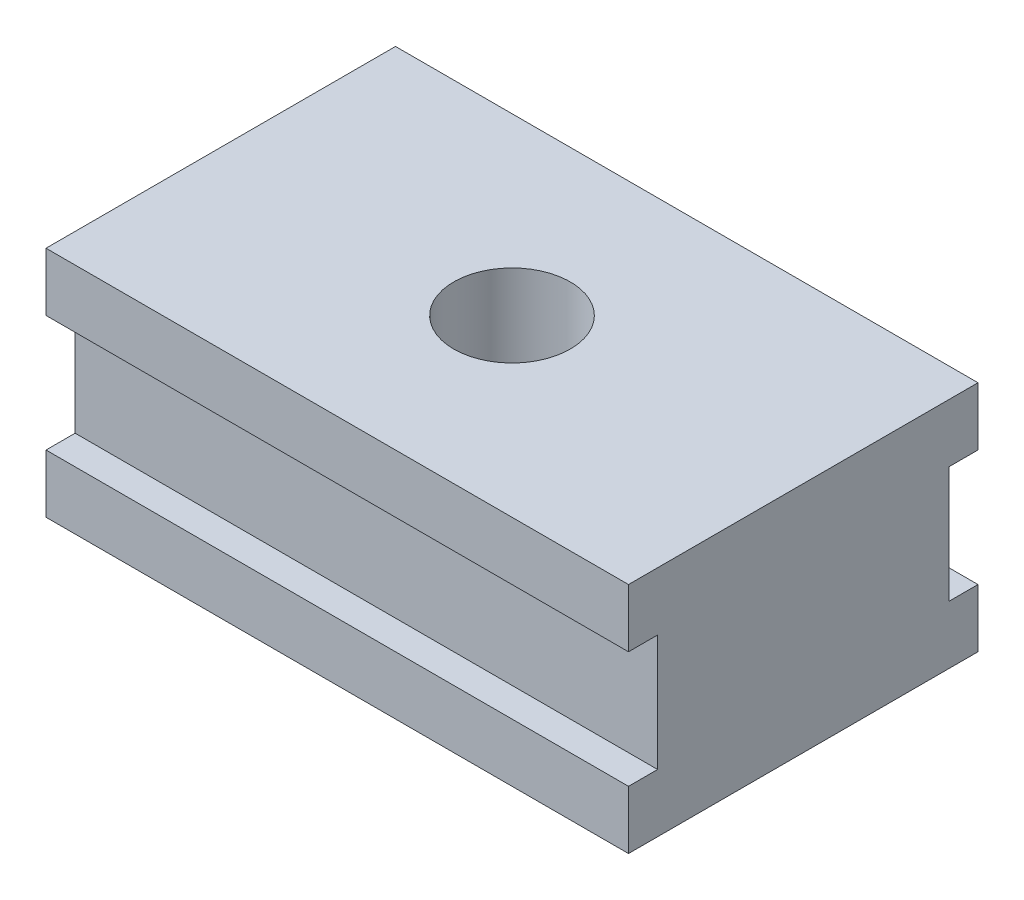
from build123d import *

# Parameters (mm, degrees)
SKETCH_1_W          = 20
SKETCH_1_H          = 8
EXTRUDE_1_DEPTH     = 12
SKETCH_2_W          = 1
SKETCH_2_H          = 4
CUT_EXTRUDE_3_DEPTH = 21
CUT_EXTRUDE_4_DEPTH = 9


with BuildPart() as part:
    # 草图1 → 凸台-拉伸1 (new body)
    with BuildSketch(Plane.XY):
        Rectangle(SKETCH_1_W, SKETCH_1_H)
    extrude(amount=EXTRUDE_1_DEPTH)

    # 草图2 → 切除-拉伸3 (cut, through all)
    with BuildSketch(Plane(origin=(10, 0, 0), x_dir=(0, 0, -1), z_dir=(1, 0, 0))):
        with Locations((-0.5, 0)):
            Rectangle(SKETCH_2_W, SKETCH_2_H)
        with Locations((-11.5, 0)):
            Rectangle(SKETCH_2_W, SKETCH_2_H)
    extrude(amount=-CUT_EXTRUDE_3_DEPTH, mode=Mode.SUBTRACT)

    # 草图3 → 切除-拉伸4 (cut, through all)
    with BuildSketch(Plane(origin=(0, 4, 0), x_dir=(1, 0, 0), z_dir=(0, 1, 0))):
        with BuildLine():
            ThreePointArc((2, -6), (1.414213562, -4.585786438), (0, -4))
            Line((0, -4), (0, -8))
            ThreePointArc((0, -8), (1.414213562, -7.414213562), (2, -6))
        make_face()
        with BuildLine():
            Line((0, -8), (0, -4))
            ThreePointArc((0, -4), (-2, -6), (0, -8))
        make_face()
    extrude(amount=-CUT_EXTRUDE_4_DEPTH, mode=Mode.SUBTRACT)


solid = part.part
